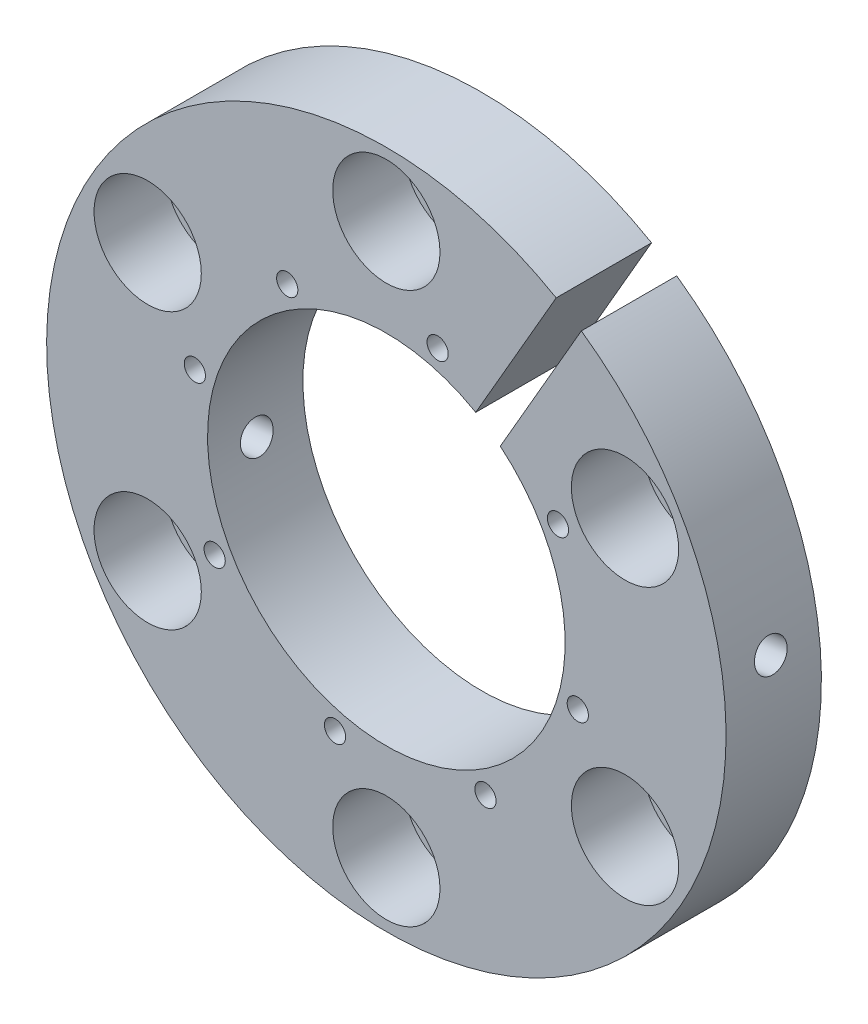
from build123d import *

# Parameters (mm, degrees)
SKETCH2_R                                = 36.195
BOSS_EXTRUDE1_DEPTH                      = 10.16
SKETCH3_R                                = 19.05
CUT_EXTRUDE1_DEPTH                       = 53.186029261
CBORE_FOR_1_4_HEX_HEAD_BOLT1_D           = 6.7564
CBORE_FOR_1_4_HEX_HEAD_BOLT1_CBORE_D     = 11.43
CBORE_FOR_1_4_HEX_HEAD_BOLT1_CBORE_DEPTH = 7.62
CIRPATTERN1_COUNT                        = 6
CIRPATTERN5_COUNT                        = 8
CUT_EXTRUDE9_DEPTH                       = 53.186029261
F_8_32_TAPPED_HOLE3_D                    = 3.4544


with BuildPart() as part:
    # Sketch2 → Boss-Extrude1 (new body)
    with BuildSketch(Plane.XY):
        Circle(SKETCH2_R)
    extrude(amount=BOSS_EXTRUDE1_DEPTH)

    # Sketch3 → Cut-Extrude1 (cut, through all)
    with BuildSketch(Plane.XY.offset(10.16)):
        Circle(SKETCH3_R)
    extrude(amount=-CUT_EXTRUDE1_DEPTH, mode=Mode.SUBTRACT)

    # CBORE for 1_4 Hex Head Bolt1 (through all)
    with Locations(Plane.XY.offset(10.16)):
        with Locations((0, 29.3624)):
            cbore_for_1_4_hex_head_bolt1 = CounterBoreHole(CBORE_FOR_1_4_HEX_HEAD_BOLT1_D / 2, CBORE_FOR_1_4_HEX_HEAD_BOLT1_CBORE_D / 2, CBORE_FOR_1_4_HEX_HEAD_BOLT1_CBORE_DEPTH)

    # CirPattern1: CBORE for 1_4 Hex Head Bolt1 ×6 about axis
    cirpattern1_axis = Axis((0, 0, 0), (0, 0, 1))
    for i in range(1, CIRPATTERN1_COUNT):
        add(cbore_for_1_4_hex_head_bolt1.rotate(cirpattern1_axis, i * 360 / CIRPATTERN1_COUNT), mode=Mode.SUBTRACT)

    # Sketch35 → 4-40 Tapped Hole1 (revolve, cut)
    with BuildSketch(Plane(origin=(5.465977373, 20.39930527, 10.16), x_dir=(0, -1, 0), z_dir=(1, 0, 0))):
        Polygon((0, 0), (0, 8.299152758), (1.1303, 7.62), (1.1303, 0), align=None)
    f_4_40_tapped_hole1 = revolve(axis=Axis((5.465977373, 20.39930527, 16.51), (0, 0, -1)), mode=Mode.SUBTRACT)

    # CirPattern5: 4-40 Tapped Hole1 ×8 about axis
    cirpattern5_axis = Axis((0, 0, 0), (0, 0, 1))
    for i in range(1, CIRPATTERN5_COUNT):
        add(f_4_40_tapped_hole1.rotate(cirpattern5_axis, i * 360 / CIRPATTERN5_COUNT), mode=Mode.SUBTRACT)

    # Sketch44 → Cut-Extrude9 (cut, through all)
    with BuildSketch(Plane.XY.offset(10.16)):
        Polygon((0, 0), (22.496225018, 38.964604709), (25.245855675, 37.377104709), (2.749630657, -1.5875), align=None)
    extrude(amount=-CUT_EXTRUDE9_DEPTH, mode=Mode.SUBTRACT)

    # 8-32 Tapped Hole3 (through all)
    with Locations(Plane(origin=(-35.885346757, -4.724395527, 5.08), x_dir=(0.13052619222, -0.991444861374, 0), z_dir=(-0.991444861374, -0.13052619222, 0))):
        with Locations((0, 0)):
            Hole(F_8_32_TAPPED_HOLE3_D / 2)


solid = part.part
